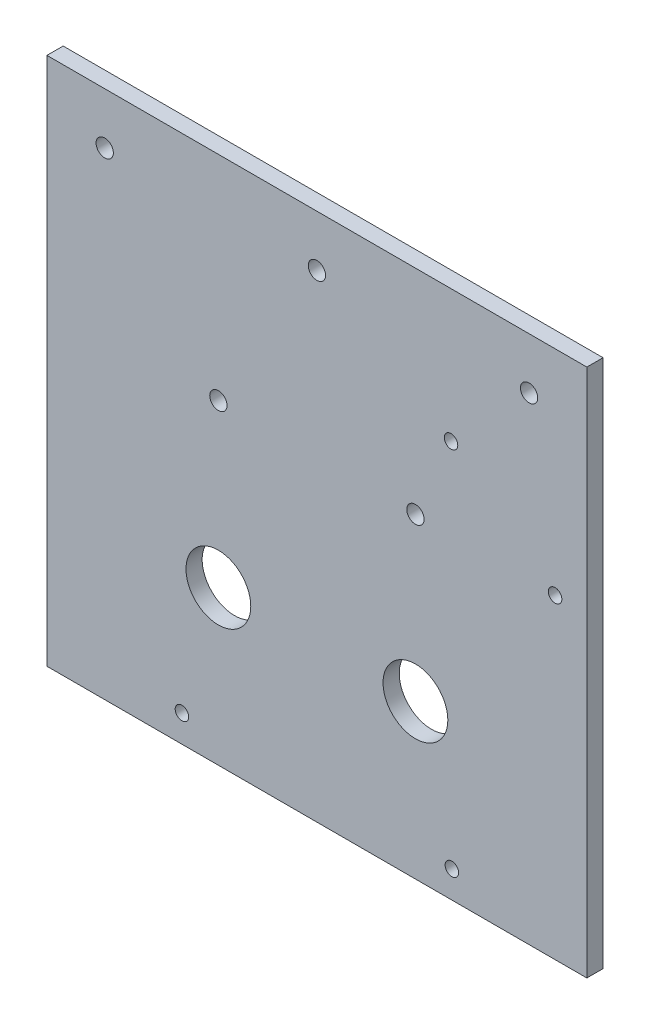
from build123d import *

# Parameters (mm, degrees)
SKETCH_1_W          = 100
SKETCH_1_H          = 99
EXTRUDE_1_DEPTH     = 3
SKETCH_2_R          = 6
SKETCH_2_R_2        = 1.6
CUT_EXTRUDE_1_DEPTH = 3
SKETCH_4_W          = 131.961579061
SKETCH_4_H          = 16.810392237
CUT_EXTRUDE_2_DEPTH = 1
M3X0_5_4_D          = 2.5
M3X0_5_4_DEPTH      = 8.5
M3X0_5_4_TIP        = 0.751075774
M3X0_5_5_D          = 2.5
M3X0_5_5_DEPTH      = 8.5
M3X0_5_5_TIP        = 0.751075774
SKETCH_11_R         = 1.6
CUT_EXTRUDE_3_DEPTH = 10
SKETCH_12_R         = 1.6
CUT_EXTRUDE_4_DEPTH = 10


with BuildPart() as part:
    # ｽｹｯﾁ1 → ﾎﾞｽ - 押し出し1 (new body)
    with BuildSketch(Plane.XY):
        Rectangle(SKETCH_1_W, SKETCH_1_H)
    extrude(amount=EXTRUDE_1_DEPTH)

    # ｽｹｯﾁ2 → ｶｯﾄ - 押し出し1 (cut)
    with BuildSketch(Plane.XY.offset(3)):
        with Locations((-18.25, -20)):
            Circle(SKETCH_2_R)
        with Locations((18.25, -20)):
            Circle(SKETCH_2_R)
        with Locations((0, 40)):
            Circle(SKETCH_2_R_2)
    extrude(amount=-CUT_EXTRUDE_1_DEPTH, mode=Mode.SUBTRACT)

    # ｽｹｯﾁ4 → ｶｯﾄ - 押し出し2 (cut)
    with BuildSketch(Plane(origin=(0, -49.5, 0), x_dir=(-1, 0, 0), z_dir=(0, -1, 0))):
        with Locations((0.945584564, -1.132272669)):
            Rectangle(SKETCH_4_W, SKETCH_4_H)
    extrude(amount=-CUT_EXTRUDE_2_DEPTH, mode=Mode.SUBTRACT)

    # M3x0.5 ねじ穴4
    with Locations(Plane(origin=(25, -43.5, 3), x_dir=(1, 0, 0), z_dir=(0, 0, 1))):
        with Locations((0, 0), (-50, 0)):
            Hole(M3X0_5_4_D / 2, depth=M3X0_5_4_DEPTH)
            with Locations((0, 0, -(M3X0_5_4_DEPTH + M3X0_5_4_TIP / 2))):  # 118° drill point
                Cone(0, M3X0_5_4_D / 2, M3X0_5_4_TIP, mode=Mode.SUBTRACT)

    # M3x0.5 ねじ穴5
    with Locations(Plane(origin=(44.122623141, 9.934763699, 0), x_dir=(-1, 0, 0), z_dir=(0, 0, -1))):
        with Locations((0, 0), (19.282623141, 15.065236301)):
            Hole(M3X0_5_5_D / 2, depth=M3X0_5_5_DEPTH)
            with Locations((0, 0, -(M3X0_5_5_DEPTH + M3X0_5_5_TIP / 2))):  # 118° drill point
                Cone(0, M3X0_5_5_D / 2, M3X0_5_5_TIP, mode=Mode.SUBTRACT)

    # ｽｹｯﾁ11 → ｶｯﾄ - 押し出し3 (cut)
    with BuildSketch(Plane(origin=(0, 0, 0), x_dir=(-1, 0, 0), z_dir=(0, 0, -1))):
        with Locations((18.25, 10)):
            Circle(SKETCH_11_R)
        with Locations((-18.25, 10)):
            Circle(SKETCH_11_R)
    extrude(amount=-CUT_EXTRUDE_3_DEPTH, mode=Mode.SUBTRACT)

    # ｽｹｯﾁ12 → ｶｯﾄ - 押し出し4 (cut)
    with BuildSketch(Plane(origin=(0, 0, 0), x_dir=(-1, 0, 0), z_dir=(0, 0, -1))):
        with Locations((-39.3, 40)):
            Circle(SKETCH_12_R)
        with Locations((39.3, 40)):
            Circle(SKETCH_12_R)
    extrude(amount=-CUT_EXTRUDE_4_DEPTH, mode=Mode.SUBTRACT)


solid = part.part
